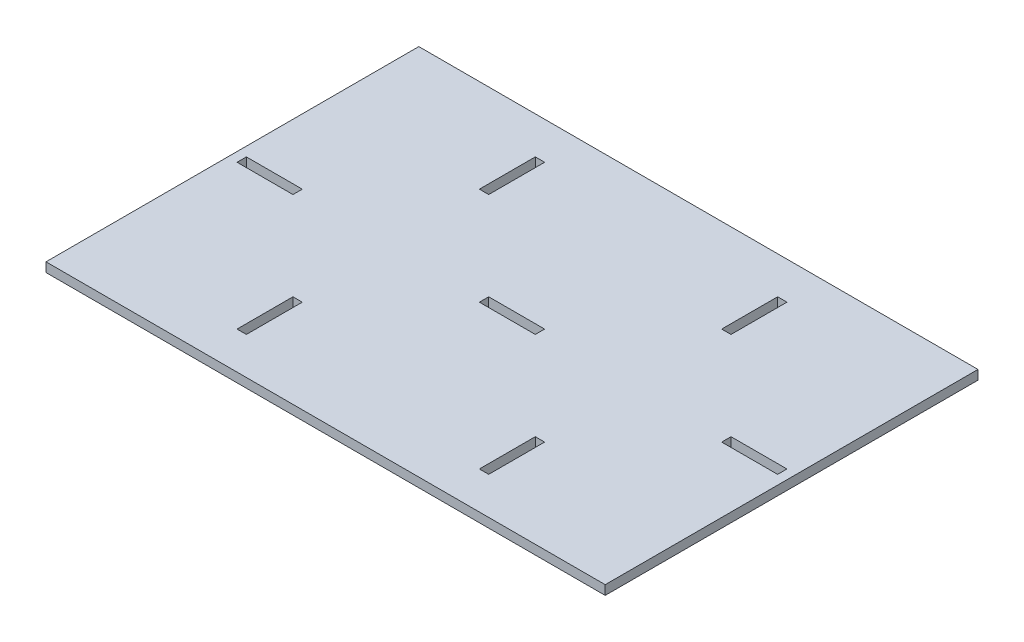
from build123d import *

# Parameters (mm, degrees)
SKETCH1_W           = 300
SKETCH1_H           = 200
BOSS_EXTRUDE1_DEPTH = 5
SKETCH2_W           = 30
SKETCH2_H           = 5
SKETCH2_W_2         = 5
SKETCH2_H_2         = 30
CUT_EXTRUDE1_DEPTH  = 5


with BuildPart() as part:
    # Sketch1 → Boss-Extrude1 (new body)
    with BuildSketch(Plane(origin=(0, 0, 0), x_dir=(1, 0, 0), z_dir=(0, 1, 0))):
        Rectangle(SKETCH1_W, SKETCH1_H)
    extrude(amount=BOSS_EXTRUDE1_DEPTH)

    # Sketch2 → Cut-Extrude1 (cut)
    with BuildSketch(Plane(origin=(0, 5, 0), x_dir=(1, 0, 0), z_dir=(0, 1, 0))):
        with Locations((-130, 0)):
            Rectangle(SKETCH2_W, SKETCH2_H)
        with Locations((130, 0)):
            Rectangle(SKETCH2_W, SKETCH2_H)
        with Locations((-65, 65)):
            Rectangle(SKETCH2_W_2, SKETCH2_H_2)
        with Locations((-65, -65)):
            Rectangle(SKETCH2_W_2, SKETCH2_H_2)
        with Locations((65, 65)):
            Rectangle(SKETCH2_W_2, SKETCH2_H_2)
        with Locations((65, -65)):
            Rectangle(SKETCH2_W_2, SKETCH2_H_2)
        Rectangle(SKETCH2_W, SKETCH2_H)
    extrude(amount=-CUT_EXTRUDE1_DEPTH, mode=Mode.SUBTRACT)


solid = part.part
